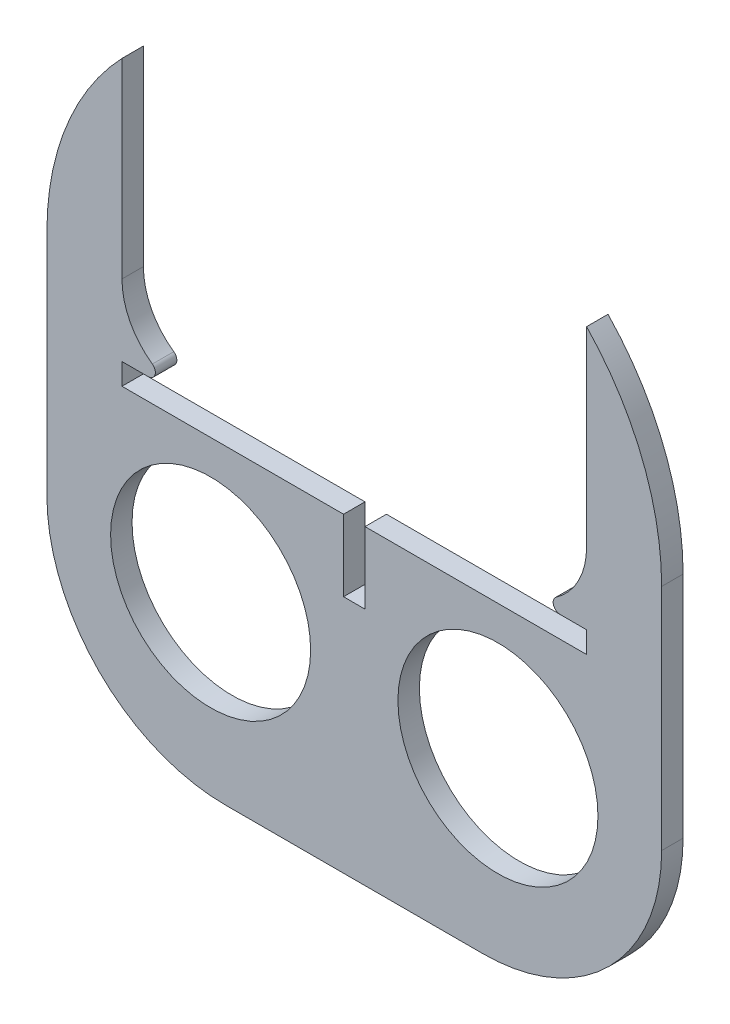
from build123d import *

# Parameters (mm, degrees)
BOSS_EXTRUDE1_DEPTH = 3
CUT_EXTRUDE1_DEPTH  = 10
SKETCH3_W           = 3
SKETCH3_H           = 10
CUT_EXTRUDE2_DEPTH  = 10
SKETCH4_R           = 13.991897225
CUT_EXTRUDE3_DEPTH  = 10
FILLET1_R           = 1


with BuildPart() as part:
    # Sketch1 → Boss-Extrude1 (new body)
    with BuildSketch(Plane.XY):
        with BuildLine():
            Line((-5, 8.5), (5, 8.5))
            ThreePointArc((5, 8.5), (31.870057685, -2.629942315), (43, -29.5))
            Line((43, -29.5), (43, -61.5))
            ThreePointArc((43, -61.5), (35.67766953, -79.17766953), (18, -86.5))
            Line((18, -86.5), (0.5, -86.5))
            Line((0.5, -86.5), (-0.5, -86.5))
            Line((-0.5, -86.5), (-18, -86.5))
            ThreePointArc((-18, -86.5), (-35.67766953, -79.17766953), (-43, -61.5))
            Line((-43, -61.5), (-43, -29.5))
            ThreePointArc((-43, -29.5), (-31.870057685, -2.629942315), (-5, 8.5))
        make_face()
    extrude(amount=BOSS_EXTRUDE1_DEPTH)

    # Sketch2 → Cut-Extrude1 (cut)
    with BuildSketch(Plane.XY.offset(3)):
        with BuildLine():
            Line((-22.5, -40), (22.5, -40))
            ThreePointArc((22.5, -40), (29.571067812, -37.071067812), (32.5, -30))
            Line((32.5, -30), (32.5, 20))
            ThreePointArc((32.5, 20), (29.571067812, 27.071067812), (22.5, 30))
            Line((22.5, 30), (-22.5, 30))
            ThreePointArc((-22.5, 30), (-29.571067812, 27.071067812), (-32.5, 20))
            Line((-32.5, 20), (-32.5, -30))
            ThreePointArc((-32.5, -30), (-29.571067812, -37.071067812), (-22.5, -40))
        make_face()
    extrude(amount=-CUT_EXTRUDE1_DEPTH, mode=Mode.SUBTRACT)

    # Sketch3 → Cut-Extrude2 (cut)
    with BuildSketch(Plane.XY.offset(3)):
        Polygon((-32.5, -40), (-32.5, -43), (-1.5, -43), (1.5, -43), (32.5, -43), (32.5, -40), (22.5, -40), (-22.5, -40), align=None)
        with Locations((0, -48)):
            Rectangle(SKETCH3_W, SKETCH3_H)
    extrude(amount=-CUT_EXTRUDE2_DEPTH, mode=Mode.SUBTRACT)

    # Sketch4 → Cut-Extrude3 (cut)
    with BuildSketch(Plane.XY.offset(3)):
        with Locations((-20.09774362, -61.766309122)):
            Circle(SKETCH4_R)
        with Locations((20.09774362, -61.766309122)):
            Circle(SKETCH4_R)
    extrude(amount=-CUT_EXTRUDE3_DEPTH, mode=Mode.SUBTRACT)

    # Fillet1
    fillet1_edges = [part.edges().sort_by_distance(p)[0] for p in [
        (22.5, -40, 1.5),
        (-22.5, -40, 1.5),
    ]]
    fillet(fillet1_edges, radius=FILLET1_R)


solid = part.part
